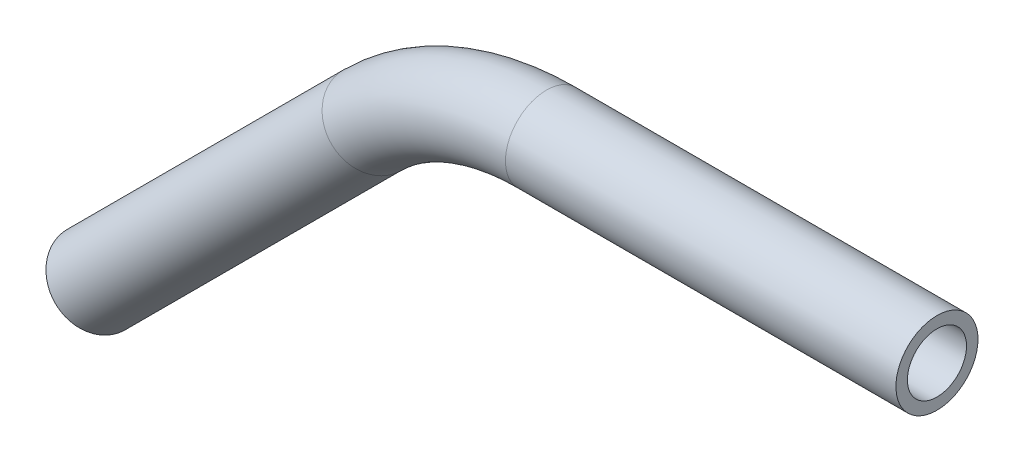
from build123d import *

# Parameters (mm, degrees)
SKETCH2_R   = 3.175
SKETCH2_R_2 = 2.286


with BuildPart() as part:
    # Sweep1: sweep along a path in Sketch1
    with BuildLine(Plane.XY) as sweep1_path:
        Line((-22.437593841, -22.437593841), (-1.076441297, -1.076441297))
        ThreePointArc((-1.076441297, -1.076441297), (5.103823498, 3.053079616), (12.393942885, 4.503174522))
        Line((12.393942885, 4.503174522), (42.603174522, 4.503174522))
    # Sketch2 → Sweep1 (sweep)
    with BuildSketch(Plane(origin=(42.603174522, 4.503174522, 0), x_dir=(0, 0, -1), z_dir=(1, 0, 0))):
        Circle(SKETCH2_R)
        Circle(SKETCH2_R_2, mode=Mode.SUBTRACT)
    sweep(path=sweep1_path.line)


solid = part.part
